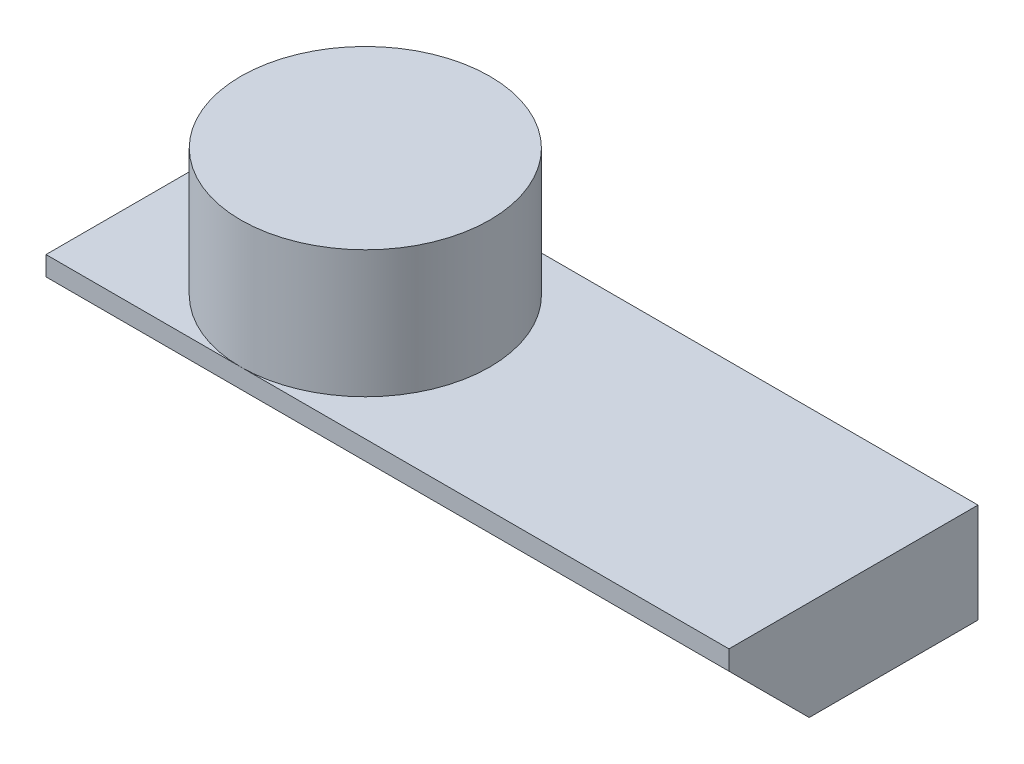
from build123d import *

# Parameters (mm, degrees)
BOSS_EXTRUDE1_DEPTH      = 1.15
BOSS_EXTRUDE1_DEPTH_BACK = 1.15
SKETCH1_R                = 2.25
BOSS_EXTRUDE2_DEPTH      = 1.8
CHAMFER2_SIZE            = 1.45
CHAMFER4_SIZE            = 1.45


with BuildPart() as part:
    # Sketch1 → Boss-Extrude1 (new, two sides: drawn at the far end of the back side and taken through both)
    with BuildSketch(Plane(origin=(0, 0, 0), x_dir=(1, 0, 0), z_dir=(0, 1, 0)).offset(-BOSS_EXTRUDE1_DEPTH_BACK)):
        Circle(SKETCH1_R)
    extrude(amount=BOSS_EXTRUDE1_DEPTH + BOSS_EXTRUDE1_DEPTH_BACK)

    # Sketch2 → Boss-Extrude2 (add)
    with BuildSketch(Plane.XZ.offset(1.15)):
        Polygon((-3.52, 2.25), (3.52, 2.25), (8.82, 2.25), (8.82, -2.25), (3.52, -2.25), (-3.52, -2.25), align=None)
    extrude(amount=BOSS_EXTRUDE2_DEPTH)

    # Chamfer2
    chamfer2_edges = [part.edges().sort_by_distance(p)[0] for p in [
        (2.65, -2.95, 2.25),
    ]]
    chamfer(chamfer2_edges, length=CHAMFER2_SIZE)

    # Chamfer4
    chamfer4_edges = [part.edges().sort_by_distance(p)[0] for p in [
        (-3.52, -2.95, -0.725),
    ]]
    chamfer(chamfer4_edges, length=CHAMFER4_SIZE)


solid = part.part
